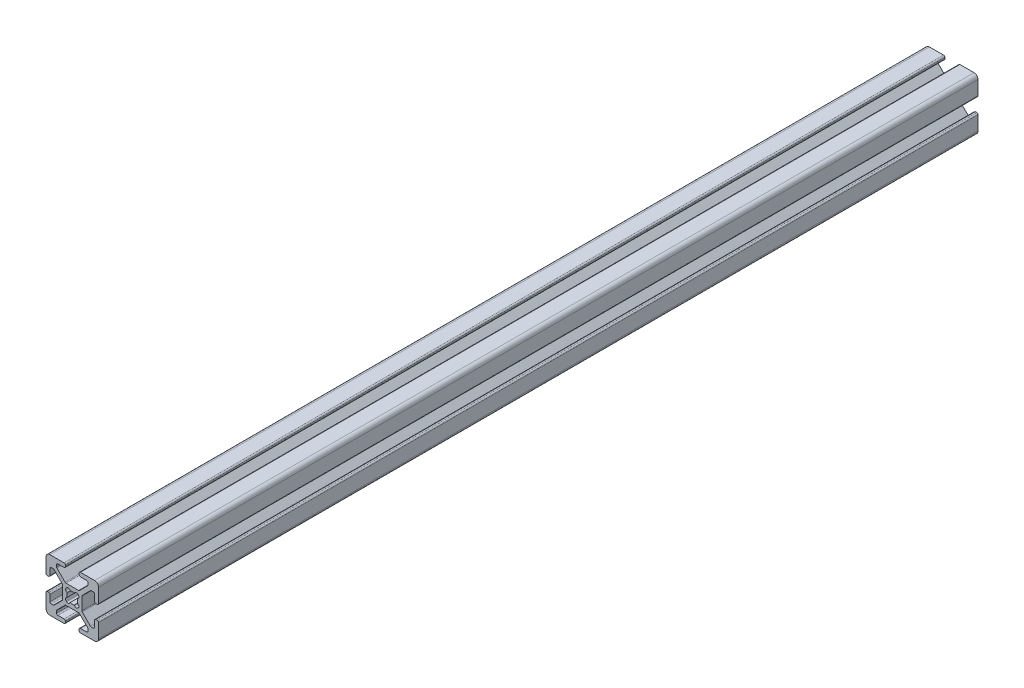
from build123d import *

# Parameters (mm, degrees)
EXTRUDE1_DEPTH = 335


with BuildPart() as part:
    # Sketch1 → Extrude1 (new body)
    with BuildSketch(Plane.XY):
        with BuildLine():
            Line((9.492, 2.63), (9.008, 2.63))
            ThreePointArc((9.008, 2.63), (8.648789755, 2.778789755), (8.5, 3.138))
            Line((8.5, 3.138), (8.5, 5.487))
            ThreePointArc((8.5, 5.487), (8.351210245, 5.846210245), (7.992, 5.995))
            Line((7.992, 5.995), (7.266080661, 5.995))
            ThreePointArc((7.266080661, 5.995), (7.071677478, 5.956330803), (6.906870417, 5.846210245))
            Line((6.906870417, 5.846210245), (3.803789755, 2.743129583))
            ThreePointArc((3.803789755, 2.743129583), (3.693669197, 2.578322522), (3.655, 2.383919339))
            Line((3.655, 2.383919339), (3.655, -2.383919339))
            ThreePointArc((3.655, -2.383919339), (3.693669197, -2.578322522), (3.803789755, -2.743129583))
            Line((3.803789755, -2.743129583), (6.906870417, -5.846210245))
            ThreePointArc((6.906870417, -5.846210245), (7.071677478, -5.956330803), (7.266080661, -5.995))
            Line((7.266080661, -5.995), (7.992, -5.995))
            ThreePointArc((7.992, -5.995), (8.351210245, -5.846210245), (8.5, -5.487))
            Line((8.5, -5.487), (8.5, -3.138))
            ThreePointArc((8.5, -3.138), (8.648789755, -2.778789755), (9.008, -2.63))
            Line((9.008, -2.63), (9.492, -2.63))
            ThreePointArc((9.492, -2.63), (9.851210245, -2.778789755), (10, -3.138))
            Line((10, -3.138), (10, -8.5))
            ThreePointArc((10, -8.5), (9.560660172, -9.560660172), (8.5, -10))
            Line((8.5, -10), (3.138, -10))
            ThreePointArc((3.138, -10), (2.778789755, -9.851210245), (2.63, -9.492))
            Line((2.63, -9.492), (2.63, -9.008))
            ThreePointArc((2.63, -9.008), (2.778789755, -8.648789755), (3.138, -8.5))
            Line((3.138, -8.5), (5.487, -8.5))
            ThreePointArc((5.487, -8.5), (5.846210245, -8.351210245), (5.995, -7.992))
            Line((5.995, -7.992), (5.995, -7.266080661))
            ThreePointArc((5.995, -7.266080661), (5.956330803, -7.071677478), (5.846210245, -6.906870417))
            Line((5.846210245, -6.906870417), (2.743129583, -3.803789755))
            ThreePointArc((2.743129583, -3.803789755), (2.578322522, -3.693669197), (2.383919339, -3.655))
            Line((2.383919339, -3.655), (-2.383919339, -3.655))
            ThreePointArc((-2.383919339, -3.655), (-2.578322522, -3.693669197), (-2.743129583, -3.803789755))
            Line((-2.743129583, -3.803789755), (-5.846210245, -6.906870417))
            ThreePointArc((-5.846210245, -6.906870417), (-5.956330803, -7.071677478), (-5.995, -7.266080661))
            Line((-5.995, -7.266080661), (-5.995, -7.992))
            ThreePointArc((-5.995, -7.992), (-5.846210245, -8.351210245), (-5.487, -8.5))
            Line((-5.487, -8.5), (-3.138, -8.5))
            ThreePointArc((-3.138, -8.5), (-2.778789755, -8.648789755), (-2.63, -9.008))
            Line((-2.63, -9.008), (-2.63, -9.492))
            ThreePointArc((-2.63, -9.492), (-2.778789755, -9.851210245), (-3.138, -10))
            Line((-3.138, -10), (-8.5, -10))
            ThreePointArc((-8.5, -10), (-9.560660172, -9.560660172), (-10, -8.5))
            Line((-10, -8.5), (-10, -3.138))
            ThreePointArc((-10, -3.138), (-9.851210245, -2.778789755), (-9.492, -2.63))
            Line((-9.492, -2.63), (-9.008, -2.63))
            ThreePointArc((-9.008, -2.63), (-8.648789755, -2.778789755), (-8.5, -3.138))
            Line((-8.5, -3.138), (-8.5, -5.487))
            ThreePointArc((-8.5, -5.487), (-8.351210245, -5.846210245), (-7.992, -5.995))
            Line((-7.992, -5.995), (-7.266080661, -5.995))
            ThreePointArc((-7.266080661, -5.995), (-7.071677478, -5.956330803), (-6.906870417, -5.846210245))
            Line((-6.906870417, -5.846210245), (-3.803789755, -2.743129583))
            ThreePointArc((-3.803789755, -2.743129583), (-3.693669197, -2.578322522), (-3.655, -2.383919339))
            Line((-3.655, -2.383919339), (-3.655, 2.383919339))
            ThreePointArc((-3.655, 2.383919339), (-3.693669197, 2.578322522), (-3.803789755, 2.743129583))
            Line((-3.803789755, 2.743129583), (-6.906870417, 5.846210245))
            ThreePointArc((-6.906870417, 5.846210245), (-7.071677478, 5.956330803), (-7.266080661, 5.995))
            Line((-7.266080661, 5.995), (-7.992, 5.995))
            ThreePointArc((-7.992, 5.995), (-8.351210245, 5.846210245), (-8.5, 5.487))
            Line((-8.5, 5.487), (-8.5, 3.138))
            ThreePointArc((-8.5, 3.138), (-8.648789755, 2.778789755), (-9.008, 2.63))
            Line((-9.008, 2.63), (-9.492, 2.63))
            ThreePointArc((-9.492, 2.63), (-9.851210245, 2.778789755), (-10, 3.138))
            Line((-10, 3.138), (-10, 8.5))
            ThreePointArc((-10, 8.5), (-9.560660172, 9.560660172), (-8.5, 10))
            Line((-8.5, 10), (-3.138, 10))
            ThreePointArc((-3.138, 10), (-2.778789755, 9.851210245), (-2.63, 9.492))
            Line((-2.63, 9.492), (-2.63, 9.008))
            ThreePointArc((-2.63, 9.008), (-2.778789755, 8.648789755), (-3.138, 8.5))
            Line((-3.138, 8.5), (-5.487, 8.5))
            ThreePointArc((-5.487, 8.5), (-5.846210245, 8.351210245), (-5.995, 7.992))
            Line((-5.995, 7.992), (-5.995, 7.266080661))
            ThreePointArc((-5.995, 7.266080661), (-5.956330803, 7.071677478), (-5.846210245, 6.906870417))
            Line((-5.846210245, 6.906870417), (-2.743129583, 3.803789755))
            ThreePointArc((-2.743129583, 3.803789755), (-2.578322522, 3.693669197), (-2.383919339, 3.655))
            Line((-2.383919339, 3.655), (2.383919339, 3.655))
            ThreePointArc((2.383919339, 3.655), (2.578322522, 3.693669197), (2.743129583, 3.803789755))
            Line((2.743129583, 3.803789755), (5.846210245, 6.906870417))
            ThreePointArc((5.846210245, 6.906870417), (5.956330803, 7.071677478), (5.995, 7.266080661))
            Line((5.995, 7.266080661), (5.995, 7.992))
            ThreePointArc((5.995, 7.992), (5.846210245, 8.351210245), (5.487, 8.5))
            Line((5.487, 8.5), (3.138, 8.5))
            ThreePointArc((3.138, 8.5), (2.778789755, 8.648789755), (2.63, 9.008))
            Line((2.63, 9.008), (2.63, 9.492))
            ThreePointArc((2.63, 9.492), (2.778789755, 9.851210245), (3.138, 10))
            Line((3.138, 10), (8.5, 10))
            ThreePointArc((8.5, 10), (9.560660172, 9.560660172), (10, 8.5))
            Line((10, 8.5), (10, 3.138))
            ThreePointArc((10, 3.138), (9.851210245, 2.778789755), (9.492, 2.63))
        make_face()
        with BuildLine():
            Line((2.124900844, -2.304505966), (2.304505966, -2.124900844))
            ThreePointArc((2.304505966, -2.124900844), (2.505938017, -1.356467811), (1.935133506, -0.803976718))
            ThreePointArc((1.935133506, -0.803976718), (2.0955, 0), (1.935133506, 0.803976718))
            ThreePointArc((1.935133506, 0.803976718), (2.505938017, 1.356467811), (2.304505966, 2.124900844))
            Line((2.304505966, 2.124900844), (2.124900844, 2.304505966))
            ThreePointArc((2.124900844, 2.304505966), (1.356467811, 2.505938017), (0.803976718, 1.935133506))
            ThreePointArc((0.803976718, 1.935133506), (0, 2.0955), (-0.803976718, 1.935133506))
            ThreePointArc((-0.803976718, 1.935133506), (-1.356467811, 2.505938017), (-2.124900844, 2.304505966))
            Line((-2.124900844, 2.304505966), (-2.304505966, 2.124900844))
            ThreePointArc((-2.304505966, 2.124900844), (-2.505938017, 1.356467811), (-1.935133506, 0.803976718))
            ThreePointArc((-1.935133506, 0.803976718), (-2.0955, 0), (-1.935133506, -0.803976718))
            ThreePointArc((-1.935133506, -0.803976718), (-2.505938017, -1.356467811), (-2.304505966, -2.124900844))
            Line((-2.304505966, -2.124900844), (-2.124900844, -2.304505966))
            ThreePointArc((-2.124900844, -2.304505966), (-1.356467811, -2.505938017), (-0.803976718, -1.935133506))
            ThreePointArc((-0.803976718, -1.935133506), (0, -2.0955), (0.803976718, -1.935133506))
            ThreePointArc((0.803976718, -1.935133506), (1.356467811, -2.505938017), (2.124900844, -2.304505966))
        make_face(mode=Mode.SUBTRACT)
    extrude(amount=-EXTRUDE1_DEPTH)


solid = part.part
